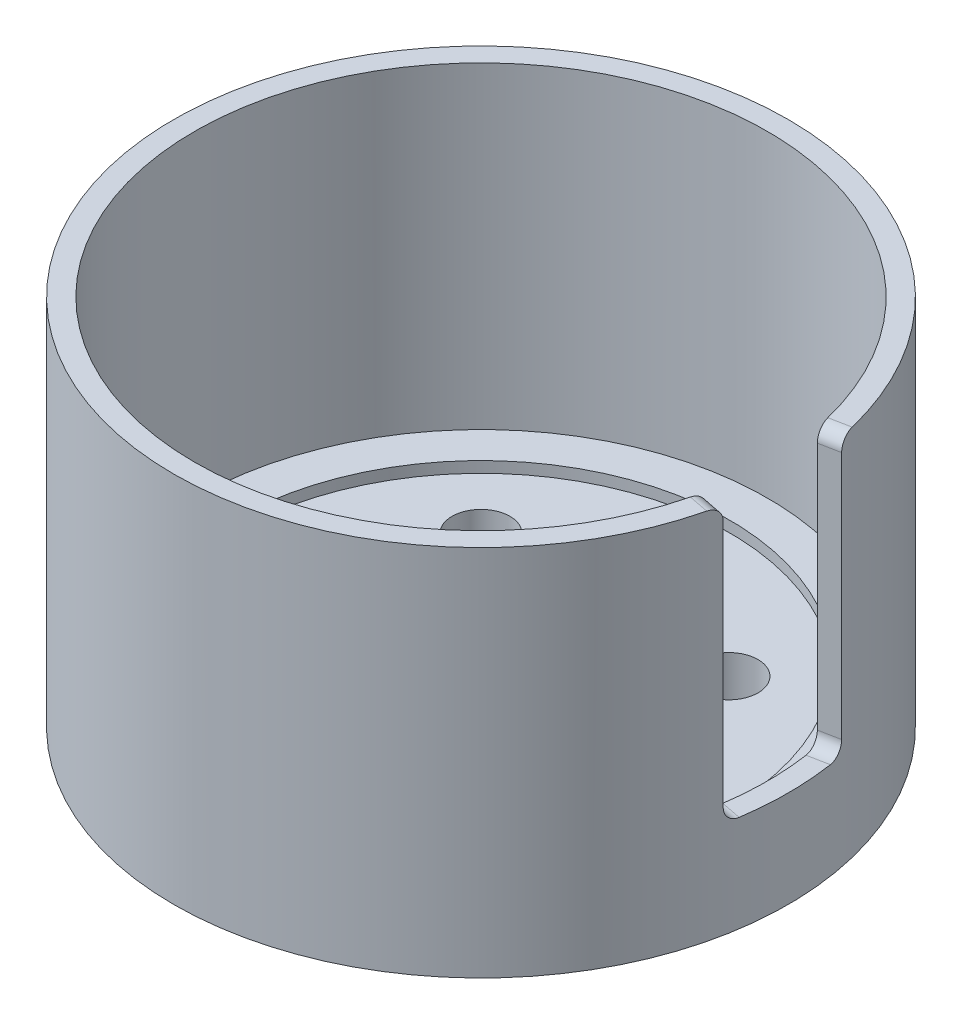
from build123d import *

# Parameters (mm, degrees)
SKETCH_1_R          = 22.25
EXTRUDE_1_DEPTH     = 27
SKETCH_2_R          = 20.75
CUT_EXTRUDE_1_DEPTH = 23
SKETCH_3_R          = 18
CUT_EXTRUDE_2_DEPTH = 0.8
SKETCH_4_R          = 3.2
SKETCH_4_R_2        = 2.1
CUT_EXTRUDE_4_DEPTH = 28
CUT_EXTRUDE_START   = 27
CUT_EXTRUDE_5_DEPTH = 20
FILLET_1_R          = 1
FILLET_2_R          = 1
SKETCH_6_W          = 0.756097561
SKETCH_6_H          = 0.292682927
EXTRUDE_2_DEPTH     = 0.6


with BuildPart() as part:
    # 草图1 → 凸台-拉伸1 (new body)
    with BuildSketch(Plane(origin=(0, 0, 0), x_dir=(1, 0, 0), z_dir=(0, 1, 0))):
        Circle(SKETCH_1_R)
    extrude(amount=EXTRUDE_1_DEPTH)

    # 草图2 → 切除-拉伸1 (cut)
    with BuildSketch(Plane(origin=(0, 27, 0), x_dir=(1, 0, 0), z_dir=(0, 1, 0))):
        Circle(SKETCH_2_R)
    extrude(amount=-CUT_EXTRUDE_1_DEPTH, mode=Mode.SUBTRACT)

    # 草图3 → 切除-拉伸2 (cut)
    with BuildSketch(Plane(origin=(0, 4, 0), x_dir=(1, 0, 0), z_dir=(0, 1, 0))):
        Circle(SKETCH_3_R)
    extrude(amount=-CUT_EXTRUDE_2_DEPTH, mode=Mode.SUBTRACT)

    # 草图4 → 切除-拉伸4 (cut, through all)
    with BuildSketch(Plane(origin=(0, 0, 0), x_dir=(1, 0, 0), z_dir=(0, 1, 0))):
        Circle(SKETCH_4_R)
        with Locations((-8.980256121, 8.980256121)):
            Circle(SKETCH_4_R_2)
        with Locations((8.980256121, 8.980256121)):
            Circle(SKETCH_4_R_2)
        with Locations((8.980256121, -8.980256121)):
            Circle(SKETCH_4_R_2)
        with Locations((-8.980256121, -8.980256121)):
            Circle(SKETCH_4_R_2)
    extrude(amount=CUT_EXTRUDE_4_DEPTH, mode=Mode.SUBTRACT)

    # 草图5 → 切除-拉伸5 (cut)
    with BuildSketch(Plane(origin=(0, 0, 0), x_dir=(1, 0, 0), z_dir=(0, 1, 0)).offset(CUT_EXTRUDE_START)):
        with BuildLine():
            Line((20.360807941, 4), (21.832673575, 4.289156627))
            ThreePointArc((21.832673575, 4.289156627), (22.25, 0), (21.832673575, -4.289156627))
            Line((21.832673575, -4.289156627), (20.360807941, -4))
            ThreePointArc((20.360807941, -4), (20.75, 0), (20.360807941, 4))
        make_face()
    extrude(amount=-CUT_EXTRUDE_5_DEPTH, mode=Mode.SUBTRACT)

    # 圆角1
    fillet_1_edges = [part.edges().sort_by_distance(p)[0] for p in [
        (21.096740758, 27, -4.144578313),
    ]]
    fillet(fillet_1_edges, radius=FILLET_1_R)

    # 圆角2
    fillet_2_edges = [part.edges().sort_by_distance(p)[0] for p in [
        (21.096740758, 27, 4.144578313),
        (21.096740758, 7, 4.144578313),
        (21.096740758, 7, -4.144578313),
    ]]
    fillet(fillet_2_edges, radius=FILLET_2_R)

    # 草图6 → 凸台-拉伸2 (add)
    with BuildSketch(Plane.XZ):
        with BuildLine():
            add(Edge.make_bspline(
                [(-4.240018428, -13.789566314), (-4.260136703, -13.824981867), (-4.299300013, -13.893923678), (-4.355654096, -13.994943629), (-4.408378639, -14.090462003), (-4.456670616, -14.180912306), (-4.501541068, -14.265819206), (-4.541662403, -14.345808054), (-4.578524463, -14.420246662), (-4.621847974, -14.511884024), (-4.670448493, -14.622279527), (-4.723109721, -14.752835072), (-4.770585411, -14.881437826), (-4.811910152, -15.009274635), (-4.848518232, -15.137470395), (-4.88006205, -15.267928435), (-4.907216645, -15.401292176), (-4.921734601, -15.491492529), (-4.929042819, -15.536898631)],
                knots=[0, 0, 0, 0, 0.000122192, 0.000237866, 0.000347025, 0.000449496, 0.000545468, 0.000635115, 0.000717947, 0.00079466, 0.000939185, 0.001079731, 0.001216937, 0.00135035, 0.001482685, 0.001616804, 0.001752905, 0.001890865, 0.001890865, 0.001890865, 0.001890865], degree=3))
            Line((-4.929042819, -15.536898631), (-5.368067209, -15.536898631))
            add(Edge.make_bspline(
                [(-5.368067209, -15.536898631), (-5.36228101, -15.504216432), (-5.350630809, -15.438412574), (-5.329693209, -15.33987366), (-5.305211108, -15.241173336), (-5.277628831, -15.142216269), (-5.247270848, -15.042923568), (-5.213588032, -14.94333986), (-5.177084646, -14.843373097), (-5.136840705, -14.742937446), (-5.093254306, -14.641283917), (-5.046015265, -14.537899978), (-4.994455776, -14.432794702), (-4.939028926, -14.325642824), (-4.880231106, -14.216271081), (-4.816557471, -14.105395925), (-4.749770027, -13.992065509), (-4.702588497, -13.916621392), (-4.678661721, -13.878362046)],
                knots=[0, 0, 0, 0, 9.9566e-05, 0.000200472, 0.000302145, 0.000404592, 0.000508626, 0.000613594, 0.000719933, 0.000827855, 0.000938144, 0.001051719, 0.001168811, 0.001289316, 0.001413623, 0.001541297, 0.001672864, 0.001808233, 0.001808233, 0.001808233, 0.001808233], degree=3))
            Line((-4.678661721, -13.878362046), (-5.630262331, -13.878362046))
            Line((-5.630262331, -13.878362046), (-5.630262331, -13.536898631))
            Line((-5.630262331, -13.536898631), (-4.240018428, -13.536898631))
            Line((-4.240018428, -13.536898631), (-4.240018428, -13.789566314))
        make_face()
        with BuildLine():
            add(Edge.make_bspline(
                [(-2.605872087, -13.789566314), (-2.625990361, -13.824981867), (-2.665153671, -13.893923678), (-2.721507754, -13.994943629), (-2.774232298, -14.090462003), (-2.822524275, -14.180912306), (-2.867394727, -14.265819206), (-2.907516062, -14.345808054), (-2.944378122, -14.420246662), (-2.987701632, -14.511884024), (-3.036302152, -14.622279527), (-3.08896338, -14.752835072), (-3.136439069, -14.881437826), (-3.17776381, -15.009274635), (-3.214371891, -15.137470395), (-3.245915709, -15.267928435), (-3.273070303, -15.401292176), (-3.28758826, -15.491492529), (-3.294896477, -15.536898631)],
                knots=[0, 0, 0, 0, 0.000122192, 0.000237866, 0.000347025, 0.000449496, 0.000545468, 0.000635115, 0.000717947, 0.00079466, 0.000939185, 0.001079731, 0.001216937, 0.00135035, 0.001482685, 0.001616804, 0.001752905, 0.001890865, 0.001890865, 0.001890865, 0.001890865], degree=3))
            Line((-3.294896477, -15.536898631), (-3.733920867, -15.536898631))
            add(Edge.make_bspline(
                [(-3.733920867, -15.536898631), (-3.728134669, -15.504216432), (-3.716484468, -15.438412574), (-3.695546868, -15.33987366), (-3.671064767, -15.241173336), (-3.643482489, -15.142216269), (-3.613124506, -15.042923568), (-3.579441691, -14.94333986), (-3.542938305, -14.843373097), (-3.502694364, -14.742937446), (-3.459107965, -14.641283917), (-3.411868923, -14.537899978), (-3.360309435, -14.432794702), (-3.304882585, -14.325642824), (-3.246084764, -14.216271081), (-3.182411129, -14.105395925), (-3.115623685, -13.992065509), (-3.068442155, -13.916621392), (-3.04451538, -13.878362046)],
                knots=[0, 0, 0, 0, 9.9566e-05, 0.000200472, 0.000302145, 0.000404592, 0.000508626, 0.000613594, 0.000719933, 0.000827855, 0.000938144, 0.001051719, 0.001168811, 0.001289316, 0.001413623, 0.001541297, 0.001672864, 0.001808233, 0.001808233, 0.001808233, 0.001808233], degree=3))
            Line((-3.04451538, -13.878362046), (-3.996115989, -13.878362046))
            Line((-3.996115989, -13.878362046), (-3.996115989, -13.536898631))
            Line((-3.996115989, -13.536898631), (-2.605872087, -13.536898631))
            Line((-2.605872087, -13.536898631), (-2.605872087, -13.789566314))
        make_face()
        with BuildLine():
            Line((-2.264408672, -15.488118144), (-2.264408672, -15.118072412))
            add(Edge.make_bspline(
                [(-2.264408672, -15.118072412), (-2.246890507, -15.128242052), (-2.212214731, -15.148372023), (-2.158075333, -15.1738077), (-2.103291945, -15.195685916), (-2.047439805, -15.213151477), (-1.990925871, -15.226964168), (-1.933627325, -15.236792346), (-1.875456058, -15.243247106), (-1.836326298, -15.243891276), (-1.816619038, -15.244215705)],
                knots=[0, 0, 0, 0, 6.0743e-05, 0.000120236, 0.000179257, 0.000237593, 0.00029564, 0.000353657, 0.000411904, 0.000471005, 0.000471005, 0.000471005, 0.000471005], degree=3))
            add(Edge.make_bspline(
                [(-1.816619038, -15.244215705), (-1.802131034, -15.243864647), (-1.773867318, -15.243179792), (-1.732553804, -15.239548131), (-1.693696965, -15.232662519), (-1.657338146, -15.223196951), (-1.623328628, -15.21095518), (-1.591921075, -15.195671544), (-1.562505708, -15.178238839), (-1.536291834, -15.157449425), (-1.512583328, -15.134667147), (-1.492004489, -15.109782635), (-1.474130595, -15.083222167), (-1.459656827, -15.054566026), (-1.448476373, -15.023860697), (-1.441210287, -14.991291033), (-1.435795579, -14.95704648), (-1.435362787, -14.933517405), (-1.43514038, -14.92142607)],
                knots=[0, 0, 0, 0, 4.3472e-05, 8.4806e-05, 0.000124279, 0.000161716, 0.000197401, 0.000232514, 0.000266369, 0.00029976, 0.000332641, 0.000364845, 0.000396449, 0.000428491, 0.00046092, 0.000494198, 0.000528475, 0.000564712, 0.000564712, 0.000564712, 0.000564712], degree=3))
            add(Edge.make_bspline(
                [(-1.43514038, -14.92142607), (-1.435330541, -14.908823803), (-1.435699307, -14.884385173), (-1.441502974, -14.848963655), (-1.449436572, -14.815837389), (-1.461611026, -14.785201792), (-1.476733542, -14.756905034), (-1.495569975, -14.731092709), (-1.518142786, -14.708080044), (-1.543648827, -14.686980769), (-1.57289253, -14.668639688), (-1.605496879, -14.653174825), (-1.641294614, -14.639709838), (-1.680439579, -14.628779089), (-1.723149376, -14.620465823), (-1.769104475, -14.614551011), (-1.818454602, -14.610557467), (-1.85243382, -14.610235534), (-1.869972697, -14.610069363)],
                knots=[0, 0, 0, 0, 3.7759e-05, 7.3224e-05, 0.000107423, 0.000139765, 0.000171822, 0.000203456, 0.000235259, 0.000268293, 0.00030255, 0.000338515, 0.000376384, 0.000417163, 0.000460287, 0.000506802, 0.000556111, 0.000608715, 0.000608715, 0.000608715, 0.000608715], degree=3))
            add(Edge.make_bspline(
                [(-1.869972697, -14.610069363), (-1.897798675, -14.610381317), (-1.955390626, -14.611026973), (-2.044853132, -14.615952612), (-2.140422975, -14.623471553), (-2.206118339, -14.630719516), (-2.240018428, -14.634459607)],
                knots=[0, 0, 0, 0, 8.3474e-05, 0.000172768, 0.000268727, 0.000371038, 0.000371038, 0.000371038, 0.000371038], degree=3))
            Line((-2.240018428, -14.634459607), (-2.164180014, -13.536898631))
            Line((-2.164180014, -13.536898631), (-1.093676965, -13.536898631))
            Line((-1.093676965, -13.536898631), (-1.093676965, -13.878362046))
            Line((-1.093676965, -13.878362046), (-1.821192209, -13.878362046))
            Line((-1.821192209, -13.878362046), (-1.849774526, -14.302142534))
            add(Edge.make_bspline(
                [(-1.849774526, -14.302142534), (-1.815492983, -14.299476354), (-1.749783755, -14.294365947), (-1.683884541, -14.293439363), (-1.652365989, -14.292996192)],
                knots=[0, 0, 0, 0, 0.000103125, 0.000197665, 0.000197665, 0.000197665, 0.000197665], degree=3))
            add(Edge.make_bspline(
                [(-1.652365989, -14.292996192), (-1.628595098, -14.293557733), (-1.582211066, -14.294653465), (-1.51446791, -14.301748063), (-1.45077902, -14.314425564), (-1.390695925, -14.331462389), (-1.334582182, -14.353883323), (-1.282450128, -14.381716273), (-1.233614351, -14.413544774), (-1.189486066, -14.451072445), (-1.150037082, -14.49265626), (-1.114601672, -14.537341368), (-1.086047069, -14.586569406), (-1.061442889, -14.638628385), (-1.043569, -14.694605827), (-1.029990197, -14.75384122), (-1.021989197, -14.816659872), (-1.021007122, -14.859792793), (-1.020506233, -14.881791924)],
                knots=[0, 0, 0, 0, 7.1315e-05, 0.000139157, 0.000204031, 0.000265906, 0.000326271, 0.000384916, 0.000442944, 0.000500816, 0.00055823, 0.000614717, 0.000671449, 0.000728569, 0.000787139, 0.000847324, 0.000910713, 0.000976697, 0.000976697, 0.000976697, 0.000976697], degree=3))
            add(Edge.make_bspline(
                [(-1.020506233, -14.881791924), (-1.020993638, -14.906220638), (-1.021949859, -14.954146406), (-1.032365934, -15.024171659), (-1.048137707, -15.090894423), (-1.070707281, -15.154198122), (-1.100050307, -15.213923247), (-1.134966285, -15.270809014), (-1.177449063, -15.323404444), (-1.225339737, -15.372663651), (-1.278861516, -15.416994989), (-1.337225761, -15.455970509), (-1.400453284, -15.488179902), (-1.46803696, -15.515083913), (-1.540268014, -15.535999717), (-1.617191046, -15.550723443), (-1.698653698, -15.559546388), (-1.754477744, -15.560698515), (-1.783082453, -15.561288875)],
                knots=[0, 0, 0, 0, 7.3234e-05, 0.000143675, 0.000211891, 0.000278671, 0.000344802, 0.000411214, 0.000478469, 0.00054719, 0.000617015, 0.000686564, 0.000757299, 0.000829482, 0.000904497, 0.000982527, 0.001064172, 0.001149973, 0.001149973, 0.001149973, 0.001149973], degree=3))
            add(Edge.make_bspline(
                [(-1.783082453, -15.561288875), (-1.806333761, -15.561077765), (-1.851973193, -15.560663381), (-1.919092517, -15.557160556), (-1.983550188, -15.551511533), (-2.045226667, -15.543578959), (-2.104113647, -15.533310439), (-2.16019147, -15.520710528), (-2.213597123, -15.506129252), (-2.247705875, -15.494038764), (-2.264408672, -15.488118144)],
                knots=[0, 0, 0, 0, 6.975e-05, 0.000136911, 0.00020157, 0.000263824, 0.000323408, 0.000380824, 0.000436209, 0.000489357, 0.000489357, 0.000489357, 0.000489357], degree=3))
        make_face()
        with Locations((-0.276603795, -14.780801071)):
            Rectangle(SKETCH_6_W, SKETCH_6_H)
        with BuildLine():
            Line((1.638030352, -13.536898631), (1.638030352, -14.805191314))
            Line((1.638030352, -14.805191314), (1.930713279, -14.805191314))
            Line((1.930713279, -14.805191314), (1.930713279, -15.097874241))
            Line((1.930713279, -15.097874241), (1.638030352, -15.097874241))
            Line((1.638030352, -15.097874241), (1.638030352, -15.536898631))
            Line((1.638030352, -15.536898631), (1.24778645, -15.536898631))
            Line((1.24778645, -15.536898631), (1.24778645, -15.097874241))
            Line((1.24778645, -15.097874241), (0.345347425, -15.097874241))
            Line((0.345347425, -15.097874241), (0.345347425, -14.802523631))
            add(Edge.make_bspline(
                [(0.345347425, -14.802523631), (0.391661769, -14.750469823), (0.484458679, -14.646173138), (0.617884544, -14.484403312), (0.747358008, -14.318604209), (0.850502432, -14.177214789), (0.929844236, -14.064113515), (0.985418981, -13.981476501), (1.037321835, -13.901270057), (1.085809845, -13.823839243), (1.129917754, -13.748528678), (1.170904198, -13.676161716), (1.208036149, -13.606078508), (1.23039856, -13.55958159), (1.241307791, -13.536898631)],
                knots=[0, 0, 0, 0, 0.00020901, 0.000418779, 0.000628952, 0.000840019, 0.000943734, 0.001043407, 0.001138755, 0.001230333, 0.001317458, 0.001400559, 0.001479828, 0.001555333, 0.001555333, 0.001555333, 0.001555333], degree=3))
            Line((1.241307791, -13.536898631), (1.638030352, -13.536898631))
        make_face()
        with BuildLine():
            Line((0.713487669, -14.805191314), (1.24778645, -14.805191314))
            Line((1.24778645, -14.805191314), (1.24778645, -14.073865095))
            add(Edge.make_bspline(
                [(1.24778645, -14.073865095), (1.236264772, -14.094288844), (1.211786659, -14.137679649), (1.169328316, -14.204516174), (1.121255716, -14.278228661), (1.075326552, -14.34297488), (1.034610654, -14.399337701), (0.999436257, -14.446038145), (0.961113179, -14.496825752), (0.918520492, -14.55097494), (0.872509717, -14.609135369), (0.823096524, -14.67133586), (0.769474607, -14.736923924), (0.732548603, -14.781949461), (0.713487669, -14.805191314)],
                knots=[0, 0, 0, 0, 7.0337e-05, 0.000149433, 0.00023748, 0.000334327, 0.000387535, 0.000446072, 0.000509716, 0.000578404, 0.000652742, 0.000732198, 0.000816716, 0.000906891, 0.000906891, 0.000906891, 0.000906891], degree=3))
        make_face(mode=Mode.SUBTRACT)
        with BuildLine():
            Line((3.052664498, -13.512508387), (3.052664498, -15.536898631))
            Line((3.052664498, -15.536898631), (2.638030352, -15.536898631))
            Line((2.638030352, -15.536898631), (2.638030352, -13.984688265))
            add(Edge.make_bspline(
                [(2.638030352, -13.984688265), (2.624011329, -13.995780516), (2.594635495, -14.019023512), (2.54412748, -14.049469174), (2.486891896, -14.078892226), (2.423893507, -14.105321303), (2.359044402, -14.128941864), (2.295308618, -14.148059109), (2.234259173, -14.162611719), (2.194104607, -14.168289352), (2.174615718, -14.171044973)],
                knots=[0, 0, 0, 0, 5.3583e-05, 0.00011228, 0.000176536, 0.000246543, 0.000317067, 0.000383501, 0.000446086, 0.000505107, 0.000505107, 0.000505107, 0.000505107], degree=3))
            Line((2.174615718, -14.171044973), (2.174615718, -13.814718753))
            add(Edge.make_bspline(
                [(2.174615718, -13.814718753), (2.203922794, -13.805844451), (2.261925083, -13.788281122), (2.346455985, -13.757466752), (2.42831594, -13.724579589), (2.506737121, -13.687814829), (2.582334898, -13.648441902), (2.655308799, -13.606814395), (2.724764887, -13.56124039), (2.769137834, -13.528707061), (2.791231572, -13.512508387)],
                knots=[0, 0, 0, 0, 9.1847e-05, 0.000181776, 0.000269813, 0.000356425, 0.000441482, 0.00052548, 0.00060835, 0.00069053, 0.00069053, 0.00069053, 0.00069053], degree=3))
            Line((2.791231572, -13.512508387), (3.052664498, -13.512508387))
        make_face()
        with BuildLine():
            add(Edge.make_bspline(
                [(3.68681084, -15.341014485), (3.687619236, -15.325652617), (3.689197101, -15.295668627), (3.703701591, -15.253117086), (3.726562795, -15.214789834), (3.758566849, -15.1822929), (3.796500869, -15.155960466), (3.838617138, -15.135984838), (3.88462088, -15.124380467), (3.916421559, -15.122978537), (3.932618767, -15.122264485)],
                knots=[0, 0, 0, 0, 4.596e-05, 8.9706e-05, 0.0001333, 0.000178849, 0.000225368, 0.000271229, 0.000317999, 0.000366548, 0.000366548, 0.000366548, 0.000366548], degree=3))
            add(Edge.make_bspline(
                [(3.932618767, -15.122264485), (3.948956536, -15.122920266), (3.980819458, -15.12419921), (4.026626079, -15.136459563), (4.068419112, -15.156478295), (4.105128968, -15.184031834), (4.136272537, -15.216607123), (4.158456876, -15.254753438), (4.172542449, -15.296597388), (4.173916725, -15.326039465), (4.174615718, -15.341014485)],
                knots=[0, 0, 0, 0, 4.8929e-05, 9.5425e-05, 0.000141105, 0.000187143, 0.000232444, 0.00027532, 0.000318586, 0.000363371, 0.000363371, 0.000363371, 0.000363371], degree=3))
            add(Edge.make_bspline(
                [(4.174615718, -15.341014485), (4.173950445, -15.356754463), (4.172658166, -15.387329003), (4.158517067, -15.430542658), (4.136597687, -15.469458695), (4.105124167, -15.501895462), (4.067975521, -15.528823853), (4.025012071, -15.547468044), (3.977846113, -15.559347618), (3.944762326, -15.560627452), (3.927664498, -15.561288875)],
                knots=[0, 0, 0, 0, 4.7062e-05, 9.1417e-05, 0.000134952, 0.000179975, 0.000225872, 0.000271763, 0.000319642, 0.000370851, 0.000370851, 0.000370851, 0.000370851], degree=3))
            add(Edge.make_bspline(
                [(3.927664498, -15.561288875), (3.911575654, -15.560644374), (3.880203119, -15.559387625), (3.835140506, -15.546954481), (3.793580175, -15.527302885), (3.756541904, -15.500036224), (3.725648274, -15.466776992), (3.702748645, -15.428605128), (3.689464829, -15.385947923), (3.687709081, -15.356222179), (3.68681084, -15.341014485)],
                knots=[0, 0, 0, 0, 4.8169e-05, 9.3928e-05, 0.0001391, 0.000185444, 0.000231025, 0.000274423, 0.000317937, 0.000363517, 0.000363517, 0.000363517, 0.000363517], degree=3))
        make_face()
        with BuildLine():
            Line((4.947100474, -15.195435217), (5.759981572, -15.195435217))
            Line((5.759981572, -15.195435217), (5.759981572, -15.536898631))
            Line((5.759981572, -15.536898631), (4.467298645, -15.536898631))
            Line((4.467298645, -15.536898631), (4.467298645, -15.389032778))
            add(Edge.make_bspline(
                [(4.467298645, -15.389032778), (4.467848906, -15.363579196), (4.468927434, -15.313689397), (4.480631421, -15.240703633), (4.498220342, -15.170964912), (4.523771124, -15.104557906), (4.555846335, -15.041364047), (4.592359369, -14.979922758), (4.635081015, -14.921212103), (4.674844217, -14.873656037), (4.710490004, -14.835860118), (4.741313807, -14.80656611), (4.775114775, -14.775671847), (4.81255196, -14.743733265), (4.85337284, -14.710444497), (4.897958434, -14.676451102), (4.945645808, -14.640716007), (4.979048726, -14.617222084), (4.996262059, -14.605115095)],
                knots=[0, 0, 0, 0, 7.6297e-05, 0.000149544, 0.000221179, 0.000291744, 0.000362473, 0.000433582, 0.000505928, 0.000580047, 0.000619405, 0.000661721, 0.000707583, 0.000756772, 0.000809328, 0.000865582, 0.000924957, 0.000988087, 0.000988087, 0.000988087, 0.000988087], degree=3))
            add(Edge.make_bspline(
                [(4.996262059, -14.605115095), (5.011839853, -14.593530788), (5.042145246, -14.570994415), (5.084890965, -14.536531725), (5.124996327, -14.504048839), (5.160435643, -14.471555199), (5.192847426, -14.440793622), (5.220990042, -14.410566405), (5.245858018, -14.381633207), (5.274120976, -14.345164467), (5.302486549, -14.298671207), (5.327241793, -14.240725577), (5.342438529, -14.180708877), (5.344375903, -14.140007212), (5.345347425, -14.119596802)],
                knots=[0, 0, 0, 0, 5.8232e-05, 0.000113286, 0.000164715, 0.000213013, 0.000257484, 0.000298736, 0.000336847, 0.00037191, 0.000437074, 0.000499575, 0.000560394, 0.000621571, 0.000621571, 0.000621571, 0.000621571], degree=3))
            add(Edge.make_bspline(
                [(5.345347425, -14.119596802), (5.345141996, -14.108916018), (5.344742241, -14.088131676), (5.341241081, -14.057919749), (5.335664942, -14.029693305), (5.327589323, -14.003525086), (5.31740309, -13.97941582), (5.304729678, -13.957617179), (5.289979881, -13.937723774), (5.272890991, -13.919852135), (5.253288338, -13.90409194), (5.231278097, -13.890766189), (5.207306282, -13.879312876), (5.180955168, -13.87013163), (5.152367521, -13.863016134), (5.121557659, -13.857657089), (5.088419207, -13.854671018), (5.065627658, -13.854210586), (5.053807791, -13.853971802)],
                knots=[0, 0, 0, 0, 3.2033e-05, 6.2334e-05, 9.1109e-05, 0.000118231, 0.000144352, 0.000169453, 0.000193691, 0.000218488, 0.000243426, 0.000268917, 0.000295509, 0.000322991, 0.000352476, 0.000383802, 0.000416718, 0.000452179, 0.000452179, 0.000452179, 0.000452179], degree=3))
            add(Edge.make_bspline(
                [(5.053807791, -13.853971802), (5.032551559, -13.854487478), (4.990058876, -13.855518351), (4.926919499, -13.866092254), (4.864357772, -13.882048921), (4.802549381, -13.904602771), (4.74156971, -13.933950583), (4.681477787, -13.969484759), (4.621797375, -14.011222721), (4.584165234, -14.04330566), (4.56485962, -14.059764485)],
                knots=[0, 0, 0, 0, 6.3716e-05, 0.000127373, 0.000191521, 0.000257226, 0.000324387, 0.000394257, 0.00046647, 0.000542542, 0.000542542, 0.000542542, 0.000542542], degree=3))
            Line((4.56485962, -14.059764485), (4.56485962, -13.685145583))
            add(Edge.make_bspline(
                [(4.56485962, -13.685145583), (4.586125143, -13.67134151), (4.628371883, -13.643917916), (4.695019882, -13.608968015), (4.763394803, -13.579123182), (4.833658574, -13.554520815), (4.906029943, -13.536069815), (4.980192092, -13.522091817), (5.056423944, -13.514059379), (5.107905583, -13.513027947), (5.133838279, -13.512508387)],
                knots=[0, 0, 0, 0, 7.6026e-05, 0.000151035, 0.000225447, 0.00029969, 0.000374098, 0.000449293, 0.000525932, 0.000603722, 0.000603722, 0.000603722, 0.000603722], degree=3))
            add(Edge.make_bspline(
                [(5.133838279, -13.512508387), (5.157360938, -13.512884664), (5.203253759, -13.513618782), (5.270120061, -13.521149856), (5.333307445, -13.532656223), (5.39256688, -13.549572048), (5.448249532, -13.570758067), (5.499908248, -13.597401621), (5.548294423, -13.628052164), (5.591930852, -13.664234211), (5.631896195, -13.703508553), (5.665991854, -13.747543196), (5.694998938, -13.795013051), (5.719259359, -13.845854967), (5.737570257, -13.900535018), (5.750258515, -13.958690098), (5.758592184, -14.020399217), (5.759510385, -14.062785027), (5.759981572, -14.084535826)],
                knots=[0, 0, 0, 0, 7.054e-05, 0.000137624, 0.000201605, 0.000263009, 0.000322246, 0.000380025, 0.00043711, 0.000493714, 0.000549765, 0.000604882, 0.000660308, 0.000716393, 0.000773517, 0.000832875, 0.000894751, 0.000959974, 0.000959974, 0.000959974, 0.000959974], degree=3))
            add(Edge.make_bspline(
                [(5.759981572, -14.084535826), (5.75943992, -14.108832522), (5.758380937, -14.156335013), (5.74881159, -14.225687847), (5.734323812, -14.291709528), (5.712653037, -14.354158662), (5.685241953, -14.413687551), (5.652592321, -14.471089217), (5.614830723, -14.526941571), (5.578428381, -14.571762867), (5.545679338, -14.60763111), (5.517256389, -14.635779089), (5.485731331, -14.66552063), (5.450471016, -14.696318859), (5.412087674, -14.72873212), (5.369955308, -14.76231474), (5.324426268, -14.797197109), (5.29266719, -14.820613364), (5.276368767, -14.832630339)],
                knots=[0, 0, 0, 0, 7.2853e-05, 0.000142436, 0.000209649, 0.000275331, 0.000340304, 0.000406008, 0.000473234, 0.000542335, 0.000579019, 0.000618902, 0.000662308, 0.000709022, 0.00075933, 0.000813015, 0.00087064, 0.000931387, 0.000931387, 0.000931387, 0.000931387], degree=3))
            add(Edge.make_bspline(
                [(5.276368767, -14.832630339), (5.26071321, -14.844404018), (5.230659087, -14.867006064), (5.187804927, -14.90024395), (5.14908416, -14.931405494), (5.114054627, -14.960381791), (5.083536153, -14.987716137), (5.056559211, -15.012568873), (5.033584214, -15.035258793), (5.009493122, -15.06238938), (4.985496094, -15.093519171), (4.963787123, -15.129277525), (4.950069752, -15.162970534), (4.948038975, -15.185174085), (4.947100474, -15.195435217)],
                knots=[0, 0, 0, 0, 5.8766e-05, 0.000112813, 0.000162689, 0.000207873, 0.000249174, 0.000285578, 0.000317915, 0.000345987, 0.000394388, 0.000435565, 0.000471382, 0.000502156, 0.000502156, 0.000502156, 0.000502156], degree=3))
        make_face()
    extrude(amount=EXTRUDE_2_DEPTH)


solid = part.part
